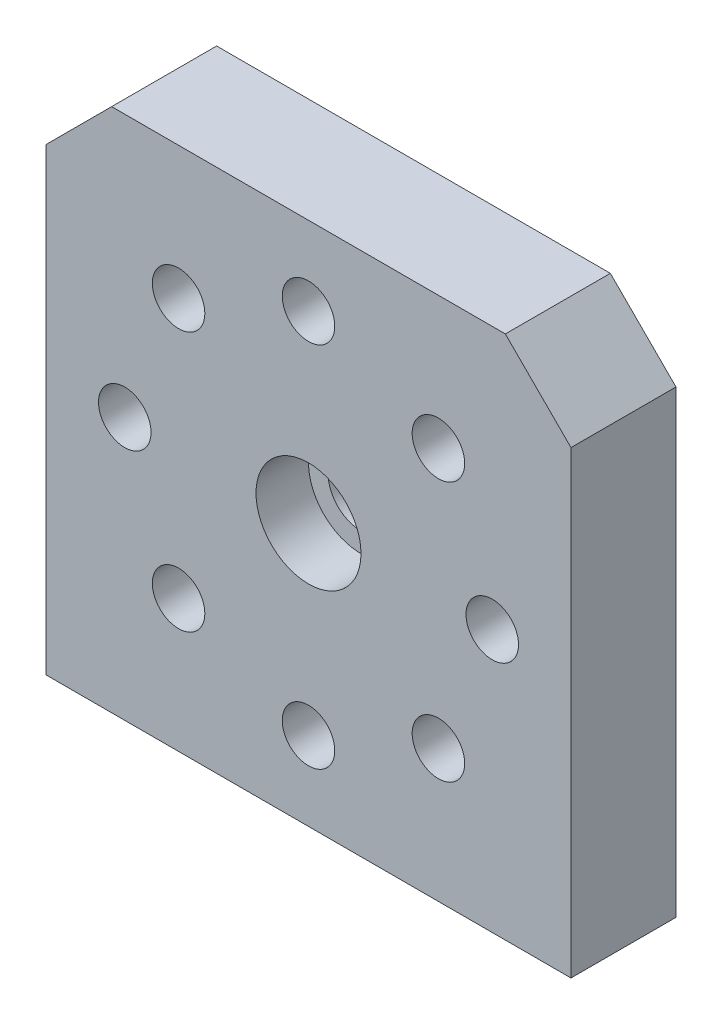
from build123d import *

# Parameters (mm, degrees)
ESQUISSE1_R      = 2.5
ESQUISSE1_R_2    = 2
EXTRUSION1_DEPTH = 8
ESQUISSE2_R      = 4
EXTRUSION2_DEPTH = 4
ESQUISSE3_R      = 2
EXTRUSION3_DEPTH = 15


with BuildPart() as part:
    # Esquisse1 → Extrusion1 (new body)
    with BuildSketch(Plane.XY):
        Polygon((-20, -20), (-20, 15), (-15, 20), (15, 20), (20, 15), (20, -20), align=None)
        Circle(ESQUISSE1_R, mode=Mode.SUBTRACT)
        with Locations((9.899494937, 9.899494937)):
            Circle(ESQUISSE1_R_2, mode=Mode.SUBTRACT)
        with Locations((0, 14)):
            Circle(ESQUISSE1_R_2, mode=Mode.SUBTRACT)
        with Locations((14, 0)):
            Circle(ESQUISSE1_R_2, mode=Mode.SUBTRACT)
        with Locations((9.899494937, -9.899494937)):
            Circle(ESQUISSE1_R_2, mode=Mode.SUBTRACT)
        with Locations((0, -14)):
            Circle(ESQUISSE1_R_2, mode=Mode.SUBTRACT)
        with Locations((-9.899494937, -9.899494937)):
            Circle(ESQUISSE1_R_2, mode=Mode.SUBTRACT)
        with Locations((-14, 0)):
            Circle(ESQUISSE1_R_2, mode=Mode.SUBTRACT)
        with Locations((-9.899494937, 9.899494937)):
            Circle(ESQUISSE1_R_2, mode=Mode.SUBTRACT)
    extrude(amount=EXTRUSION1_DEPTH)

    # Esquisse2 → Extrusion2 (cut)
    with BuildSketch(Plane.XY.offset(8)):
        Circle(ESQUISSE2_R)
    extrude(amount=-EXTRUSION2_DEPTH, mode=Mode.SUBTRACT)

    # Esquisse3 → Extrusion3 (cut)
    with BuildSketch(Plane.XZ.offset(20)):
        with Locations((-15.5, 4)):
            Circle(ESQUISSE3_R)
        with Locations((15.5, 4)):
            Circle(ESQUISSE3_R)
    extrude(amount=-EXTRUSION3_DEPTH, mode=Mode.SUBTRACT)


solid = part.part
